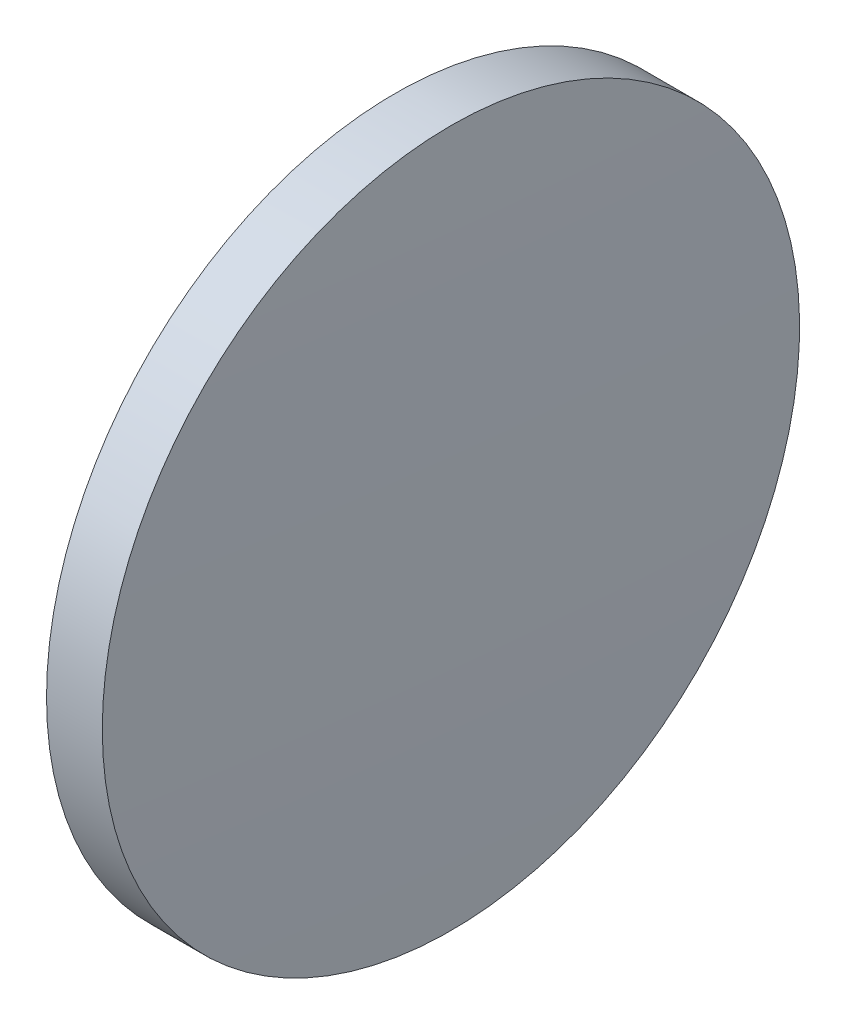
from build123d import *


with BuildPart() as part:
    # 草图1 → 旋转1 (revolve)
    with BuildSketch(Plane.XY):
        with BuildLine():
            Line((426.577728221, 122.387071527), (426.577728221, 134.887071527))
            Line((426.577728221, 134.887071527), (428.577728221, 134.887071527))
            ThreePointArc((428.577728221, 134.887071527), (428.690226871, 128.63752151), (428.727728221, 122.387071527))
            Line((428.727728221, 122.387071527), (426.577728221, 122.387071527))
        make_face()
    revolve(axis=Axis((421.835696979, 122.387071527, 0), (1, 0, 0)))


solid = part.part
